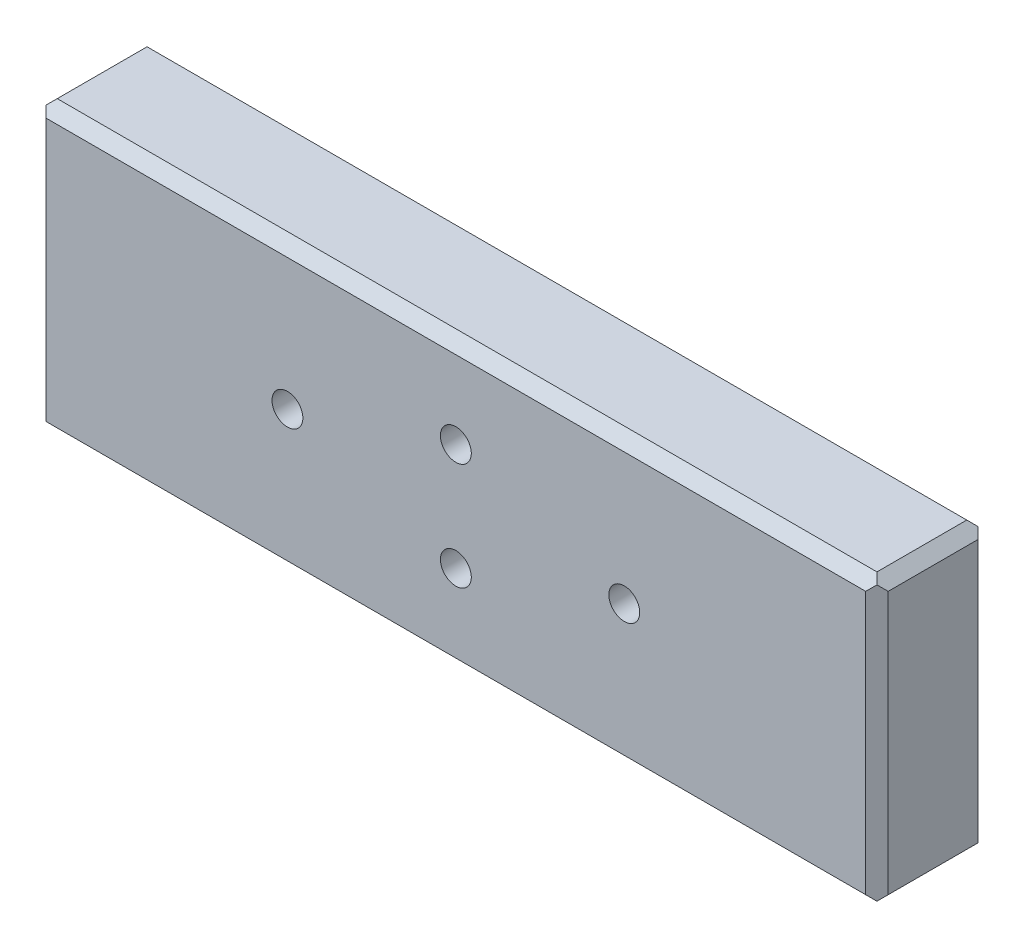
from build123d import *

# Parameters (mm, degrees)
CROQUIS1_W              = 150
CROQUIS1_H              = 50.8
SALIENTE_EXTRUIR1_DEPTH = 20
CROQUIS2_R              = 2.75
CORTAR_EXTRUIR1_DEPTH   = 21
CROQUIS3_R              = 5
CORTAR_EXTRUIR2_DEPTH   = 5
CHAFL_N1_SIZE           = 2
CHAFL_N2_SIZE           = 2
CHAFL_N3_SIZE           = 2


with BuildPart() as part:
    # Croquis1 → Saliente-Extruir1 (new body)
    with BuildSketch(Plane.XY):
        Rectangle(CROQUIS1_W, CROQUIS1_H)
    extrude(amount=SALIENTE_EXTRUIR1_DEPTH)

    # Croquis2 → Cortar-Extruir1 (cut, through all)
    with BuildSketch(Plane(origin=(0, 0, 0), x_dir=(-1, 0, 0), z_dir=(0, 0, -1))):
        with Locations((0, 9.55)):
            Circle(CROQUIS2_R)
        with Locations((0, -9.55)):
            Circle(CROQUIS2_R)
        with Locations((30, 0)):
            Circle(CROQUIS2_R)
        with Locations((-30, 0)):
            Circle(CROQUIS2_R)
    extrude(amount=-CORTAR_EXTRUIR1_DEPTH, mode=Mode.SUBTRACT)

    # Croquis3 → Cortar-Extruir2 (cut)
    with BuildSketch(Plane(origin=(0, 0, 0), x_dir=(-1, 0, 0), z_dir=(0, 0, -1))):
        with Locations((0, 9.55)):
            Circle(CROQUIS3_R)
        with Locations((0, -9.55)):
            Circle(CROQUIS3_R)
    extrude(amount=-CORTAR_EXTRUIR2_DEPTH, mode=Mode.SUBTRACT)

    # Chaflán1
    chafl_n1_edges = [part.edges().sort_by_distance(p)[0] for p in [
        (0, -25.4, 0),
        (-75, 0, 0),
        (0, 25.4, 0),
        (75, 0, 0),
    ]]
    chamfer(chafl_n1_edges, length=CHAFL_N1_SIZE)

    # Chaflán2
    chafl_n2_edges = [part.edges().sort_by_distance(p)[0] for p in [
        (-75, 0, 20),
        (0, -25.4, 20),
        (75, 0, 20),
        (0, 25.4, 20),
    ]]
    chamfer(chafl_n2_edges, length=CHAFL_N2_SIZE)

    # Chaflán3
    chafl_n3_edges = [part.edges().sort_by_distance(p)[0] for p in [
        (-75, 25.4, 10),
        (-75, -25.4, 10),
        (75, 25.4, 10),
        (75, -25.4, 10),
    ]]
    chamfer(chafl_n3_edges, length=CHAFL_N3_SIZE)


solid = part.part
